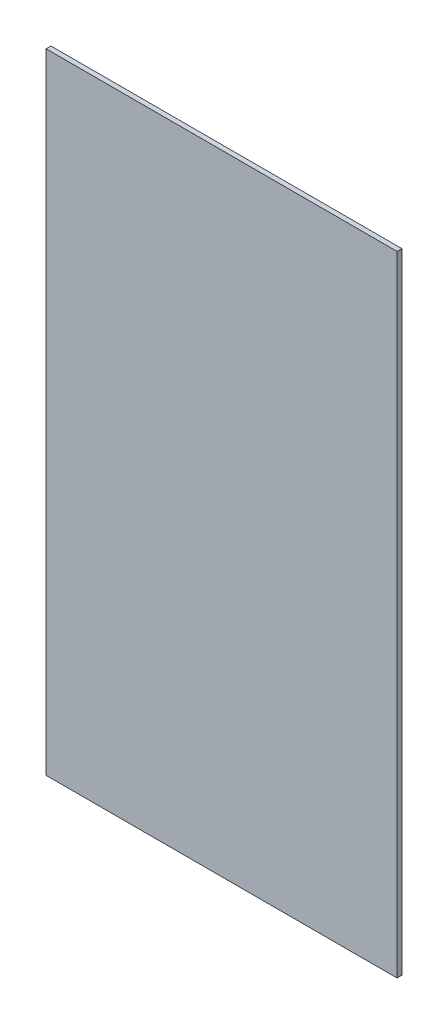
from build123d import *

# Parameters (mm, degrees)
SKETCH1_W           = 9.2075
SKETCH1_H           = 16.51
BOSS_EXTRUDE1_DEPTH = 0.127


with BuildPart() as part:
    # Sketch1 → Boss-Extrude1 (new body)
    with BuildSketch(Plane.XY):
        with Locations((-14.669644351, 41.878696913)):
            Rectangle(SKETCH1_W, SKETCH1_H)
    extrude(amount=BOSS_EXTRUDE1_DEPTH)


solid = part.part
